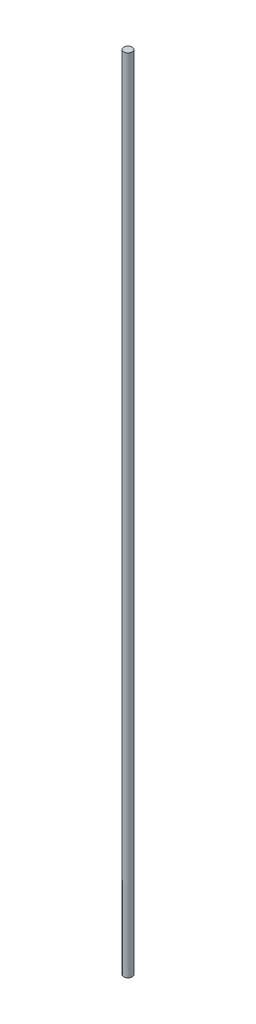
from build123d import *

# Parameters (mm, degrees)
ESQUISSE1_R      = 1.5
EXTRUSION1_DEPTH = 284


with BuildPart() as part:
    # Esquisse1 → Extrusion1 (new body)
    with BuildSketch(Plane(origin=(0, 0, 0), x_dir=(1, 0, 0), z_dir=(0, 1, 0))):
        with Locations(Location((0, 0, 0), (0, 0, 270))):  # turned: the seam where the file's is
            Circle(ESQUISSE1_R)
    extrude(amount=EXTRUSION1_DEPTH)


solid = part.part
